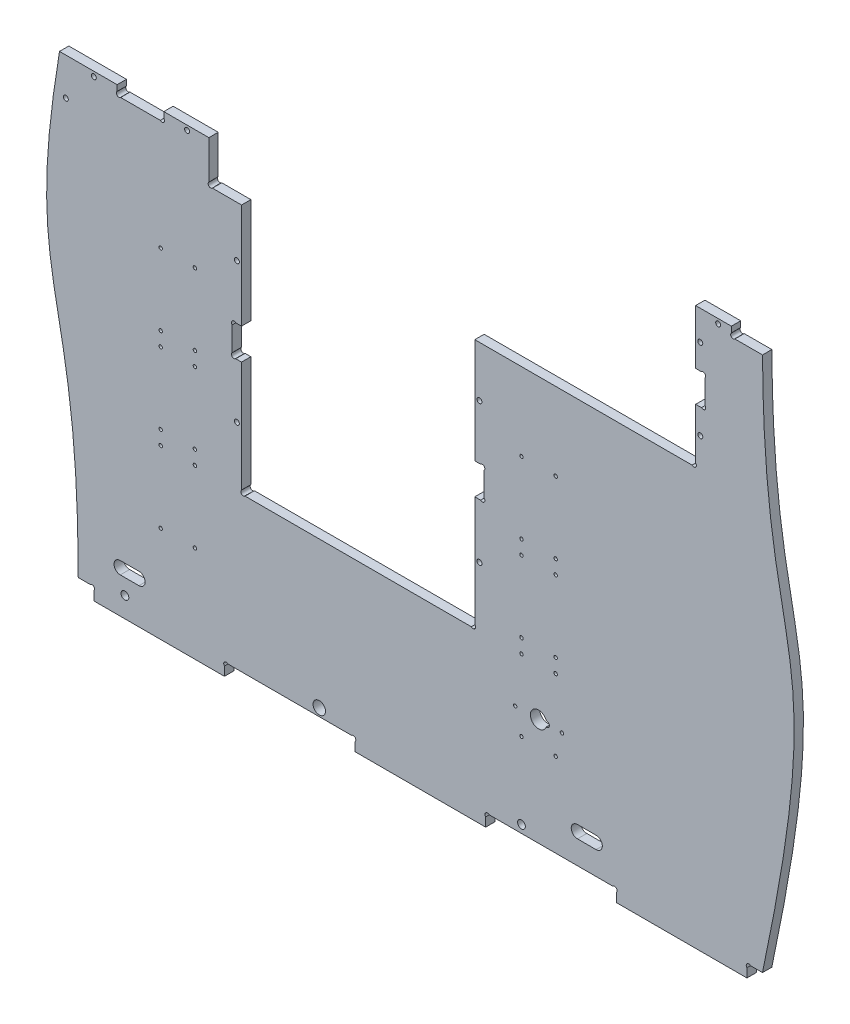
from build123d import *

# Parameters (mm, degrees)
ESQUISSE1_R        = 1.6
ESQUISSE1_R_2      = 1.1
ESQUISSE1_R_3      = 2.5
ESQUISSE1_R_4      = 4
BOSS_EXTRU_1_DEPTH = 6


with BuildPart() as part:
    # Esquisse1 → Boss.-Extru.1 (new body)
    with BuildSketch(Plane.XY):
        with BuildLine():
            Line((0, 0), (84, 0))
            Line((84, 0), (84, 5.7372583))
            ThreePointArc((84, 5.7372583), (84, 8), (86.2627417, 8))
            Line((86.2627417, 8), (165.7372583, 8))
            ThreePointArc((165.7372583, 8), (168, 8), (168, 5.7372583))
            Line((168, 5.7372583), (168, 0))
            Line((168, 0), (252, 0))
            Line((252, 0), (252, 5.7372583))
            ThreePointArc((252, 5.7372583), (252, 8), (254.2627417, 8))
            Line((254.2627417, 8), (333.7372583, 8))
            ThreePointArc((333.7372583, 8), (336, 8), (336, 5.7372583))
            Line((336, 5.7372583), (336, 0))
            Line((336, 0), (420, 0))
            Line((420, 0), (420, 5.7372583))
            ThreePointArc((420, 5.7372583), (420, 8), (422.2627417, 8))
            Line((422.2627417, 8), (430, 8))
            add(Edge.make_bspline(
                [(430, 8), (475.266946004, 222.528599588), (430.979471743, 171.685319114), (430.015895123, 352)],
                knots=[0, 0, 0, 0, 0.989181159, 0.989181159, 0.989181159, 0.989181159], degree=3))
            Line((430.015895123, 352), (412.2627417, 352))
            ThreePointArc((412.2627417, 352), (410, 352), (410, 354.2627417))
            Line((410, 354.2627417), (410, 358))
            Line((410, 358), (387, 358))
            Line((387, 358), (387, 323))
            Line((387, 323), (390.7372583, 323))
            ThreePointArc((390.7372583, 323), (393, 323), (393, 320.7372583))
            Line((393, 320.7372583), (393, 305.2627417))
            ThreePointArc((393, 305.2627417), (393, 303), (390.7372583, 303))
            Line((390.7372583, 303), (387, 303))
            Line((387, 303), (387, 270.2627417))
            ThreePointArc((387, 270.2627417), (387, 268), (384.7372583, 268))
            Line((384.7372583, 268), (245, 268))
            Line((245, 268), (245, 200.5))
            Line((245, 200.5), (248.7372583, 200.5))
            ThreePointArc((248.7372583, 200.5), (251, 200.5), (251, 198.2372583))
            Line((251, 198.2372583), (251, 182.7627417))
            ThreePointArc((251, 182.7627417), (251, 180.5), (248.7372583, 180.5))
            Line((248.7372583, 180.5), (245, 180.5))
            Line((245, 180.5), (245, 109.2627417))
            ThreePointArc((245, 109.2627417), (245, 107), (242.7372583, 107))
            Line((242.7372583, 107), (97.2627417, 107))
            ThreePointArc((97.2627417, 107), (95, 107), (95, 109.2627417))
            Line((95, 109.2627417), (95, 180.5))
            Line((95, 180.5), (91.2627417, 180.5))
            ThreePointArc((91.2627417, 180.5), (89, 180.5), (89, 182.7627417))
            Line((89, 182.7627417), (89, 198.2372583))
            ThreePointArc((89, 198.2372583), (89, 200.5), (91.2627417, 200.5))
            Line((91.2627417, 200.5), (95, 200.5))
            Line((95, 200.5), (95, 268))
            Line((95, 268), (76.2627417, 268))
            ThreePointArc((76.2627417, 268), (74, 268), (74, 270.2627417))
            Line((74, 270.2627417), (74, 295))
            Line((74, 295), (45, 295))
            Line((45, 295), (45, 291.2627417))
            ThreePointArc((45, 291.2627417), (45, 289), (42.7372583, 289))
            Line((42.7372583, 289), (17.2627417, 289))
            ThreePointArc((17.2627417, 289), (15, 289), (15, 291.2627417))
            Line((15, 291.2627417), (15, 295))
            Line((15, 295), (-22.060775094, 295))
            add(Edge.make_bspline(
                [(-22.060775094, 295), (-46.149436115, 150.219644472), (-10, 174.610905879), (-10, 8)],
                knots=[0.111212201, 0.111212201, 0.111212201, 0.111212201, 1, 1, 1, 1], degree=3))
            Line((-10, 8), (-2.2627417, 8))
            ThreePointArc((-2.2627417, 8), (0, 8), (0, 5.7372583))
            Line((0, 5.7372583), (0, 0))
        make_face()
        with Locations((401.5, 355)):
            Circle(ESQUISSE1_R, mode=Mode.SUBTRACT)
        with Locations((92, 145.5)):
            Circle(ESQUISSE1_R, mode=Mode.SUBTRACT)
        with Locations(Location((92, 235.5, 0), (0, 0, 180))):  # turned: the seam where the file's is
            Circle(ESQUISSE1_R, mode=Mode.SUBTRACT)
        with Locations((275, 62)):
            Circle(ESQUISSE1_R_2, mode=Mode.SUBTRACT)
        with Locations((297, 62)):
            Circle(ESQUISSE1_R_2, mode=Mode.SUBTRACT)
        with Locations((248, 235.5)):
            Circle(ESQUISSE1_R, mode=Mode.SUBTRACT)
        with Locations(Location((248, 145.5, 0), (0, 0, 180))):  # turned: the seam where the file's is
            Circle(ESQUISSE1_R, mode=Mode.SUBTRACT)
        with Locations((297, 108)):
            Circle(ESQUISSE1_R_2, mode=Mode.SUBTRACT)
        with Locations((275, 108)):
            Circle(ESQUISSE1_R_2, mode=Mode.SUBTRACT)
        with Locations((-18, 271)):
            Circle(ESQUISSE1_R, mode=Mode.SUBTRACT)
        with Locations((275, 117)):
            Circle(ESQUISSE1_R_2, mode=Mode.SUBTRACT)
        with Locations((297, 117)):
            Circle(ESQUISSE1_R_2, mode=Mode.SUBTRACT)
        with Locations(Location((297, 163, 0), (0, 0, 180))):  # turned: the seam where the file's is
            Circle(ESQUISSE1_R_2, mode=Mode.SUBTRACT)
        with Locations((390, 339)):
            Circle(ESQUISSE1_R, mode=Mode.SUBTRACT)
        with Locations(Location((390, 287, 0), (0, 0, 180))):  # turned: the seam where the file's is
            Circle(ESQUISSE1_R, mode=Mode.SUBTRACT)
        with Locations(Location((275, 163, 0), (0, 0, 180))):  # turned: the seam where the file's is
            Circle(ESQUISSE1_R_2, mode=Mode.SUBTRACT)
        with Locations(Location((275, 172, 0), (0, 0, 180))):  # turned: the seam where the file's is
            Circle(ESQUISSE1_R_2, mode=Mode.SUBTRACT)
        with Locations(Location((297, 172, 0), (0, 0, 180))):  # turned: the seam where the file's is
            Circle(ESQUISSE1_R_2, mode=Mode.SUBTRACT)
        with Locations(Location((297, 218, 0), (0, 0, 180))):  # turned: the seam where the file's is
            Circle(ESQUISSE1_R_2, mode=Mode.SUBTRACT)
        with Locations(Location((275, 218, 0), (0, 0, 180))):  # turned: the seam where the file's is
            Circle(ESQUISSE1_R_2, mode=Mode.SUBTRACT)
        with Locations((20, 13)):
            Circle(ESQUISSE1_R_3, mode=Mode.SUBTRACT)
        with Locations(Location((43, 62, 0), (0, 0, 180))):  # turned: the seam where the file's is
            Circle(ESQUISSE1_R_2, mode=Mode.SUBTRACT)
        with Locations(Location((65, 62, 0), (0, 0, 180))):  # turned: the seam where the file's is
            Circle(ESQUISSE1_R_2, mode=Mode.SUBTRACT)
        with Locations(Location((43, 117, 0), (0, 0, 180))):  # turned: the seam where the file's is
            Circle(ESQUISSE1_R_2, mode=Mode.SUBTRACT)
        with Locations(Location((65, 117, 0), (0, 0, 180))):  # turned: the seam where the file's is
            Circle(ESQUISSE1_R_2, mode=Mode.SUBTRACT)
        with Locations(Location((65, 108, 0), (0, 0, 180))):  # turned: the seam where the file's is
            Circle(ESQUISSE1_R_2, mode=Mode.SUBTRACT)
        with Locations(Location((43, 108, 0), (0, 0, 180))):  # turned: the seam where the file's is
            Circle(ESQUISSE1_R_2, mode=Mode.SUBTRACT)
        with Locations((43, 172)):
            Circle(ESQUISSE1_R_2, mode=Mode.SUBTRACT)
        with Locations((65, 172)):
            Circle(ESQUISSE1_R_2, mode=Mode.SUBTRACT)
        with Locations((65, 163)):
            Circle(ESQUISSE1_R_2, mode=Mode.SUBTRACT)
        with Locations((43, 163)):
            Circle(ESQUISSE1_R_2, mode=Mode.SUBTRACT)
        with Locations((65, 218)):
            Circle(ESQUISSE1_R_2, mode=Mode.SUBTRACT)
        with Locations((43, 218)):
            Circle(ESQUISSE1_R_2, mode=Mode.SUBTRACT)
        with Locations((145, 13)):
            Circle(ESQUISSE1_R_4, mode=Mode.SUBTRACT)
        with Locations((275, 13)):
            Circle(ESQUISSE1_R_3, mode=Mode.SUBTRACT)
        with Locations((60, 292)):
            Circle(ESQUISSE1_R, mode=Mode.SUBTRACT)
        with Locations((301, 77)):
            Circle(ESQUISSE1_R_2, mode=Mode.SUBTRACT)
        with Locations(Location((0, 292, 0), (0, 0, 180))):  # turned: the seam where the file's is
            Circle(ESQUISSE1_R, mode=Mode.SUBTRACT)
        with Locations(Location((271, 77, 0), (0, 0, 180))):  # turned: the seam where the file's is
            Circle(ESQUISSE1_R_2, mode=Mode.SUBTRACT)
        with BuildLine():
            Line((323, 31), (311, 31))
            ThreePointArc((311, 31), (307, 27), (311, 23))
            Line((311, 23), (323, 23))
            ThreePointArc((323, 23), (327, 27), (323, 31))
        make_face(mode=Mode.SUBTRACT)
        with BuildLine():
            Line((29, 23), (17, 23))
            ThreePointArc((17, 23), (13, 27), (17, 31))
            Line((17, 31), (29, 31))
            ThreePointArc((29, 31), (33, 27), (29, 23))
        make_face(mode=Mode.SUBTRACT)
        with BuildLine():
            Line((291.2, 78.75), (290.949747468, 78.75))
            ThreePointArc((290.949747468, 78.75), (280.75, 77), (290.949747468, 75.25))
            Line((290.949747468, 75.25), (291.2, 75.25))
            ThreePointArc((291.2, 75.25), (292.95, 77), (291.2, 78.75))
        make_face(mode=Mode.SUBTRACT)
    extrude(amount=BOSS_EXTRU_1_DEPTH)


solid = part.part
